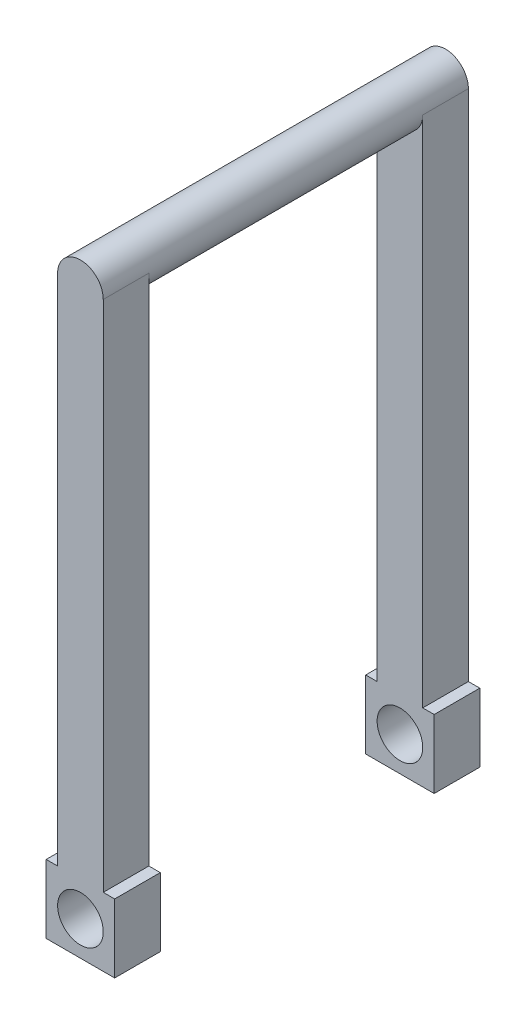
from build123d import *

# Parameters (mm, degrees)
SKETCH2_R           = 6.35
BOSS_EXTRUDE1_DEPTH = 76.2
SKETCH3_W           = 12.7
SKETCH3_H           = 152.4
BOSS_EXTRUDE2_DEPTH = 12.7
BOSS_EXTRUDE3_DEPTH = 12.7
SKETCH6_W           = 12.7
SKETCH6_H           = 152.4
BOSS_EXTRUDE4_DEPTH = 12.7
BOSS_EXTRUDE5_DEPTH = 12.7
SKETCH8_W           = 19.05
SKETCH8_H           = 19.05
BOSS_EXTRUDE6_DEPTH = 101.6
SKETCH9_W           = 76.2
SKETCH9_H           = 29.319846112
CUT_EXTRUDE1_DEPTH  = 198.12
CUT_EXTRUDE2_DEPTH  = 102.6


with BuildPart() as part:
    # Sketch2 → Boss-Extrude1 (new body)
    with BuildSketch(Plane.XY):
        Circle(SKETCH2_R)
    extrude(amount=BOSS_EXTRUDE1_DEPTH)

    # Sketch3 → Boss-Extrude2 (add)
    with BuildSketch(Plane.XY.offset(76.2)):
        with Locations((0, -76.2)):
            Rectangle(SKETCH3_W, SKETCH3_H)
    extrude(amount=BOSS_EXTRUDE2_DEPTH)

    # Sketch4 → Boss-Extrude3 (add)
    with BuildSketch(Plane.XY.offset(76.2)):
        with BuildLine():
            Line((-6.35, 0), (6.35, 0))
            ThreePointArc((6.35, 0), (0, 6.35), (-6.35, 0))
        make_face()
    extrude(amount=BOSS_EXTRUDE3_DEPTH)

    # Sketch6 → Boss-Extrude4 (add)
    with BuildSketch(Plane(origin=(0, 0, 0), x_dir=(-1, 0, 0), z_dir=(0, 0, -1))):
        with Locations((0, -76.2)):
            Rectangle(SKETCH6_W, SKETCH6_H)
    extrude(amount=BOSS_EXTRUDE4_DEPTH)

    # Sketch7 → Boss-Extrude5 (add)
    with BuildSketch(Plane(origin=(0, 0, 0), x_dir=(-1, 0, 0), z_dir=(0, 0, -1))):
        with BuildLine():
            Line((-6.35, 0), (6.35, 0))
            ThreePointArc((6.35, 0), (0, 6.35), (-6.35, 0))
        make_face()
    extrude(amount=BOSS_EXTRUDE5_DEPTH)

    # Sketch8 → Boss-Extrude6 (add)
    with BuildSketch(Plane(origin=(0, 0, -12.7), x_dir=(-1, 0, 0), z_dir=(0, 0, -1))):
        with Locations((0, -152.4)):
            Rectangle(SKETCH8_W, SKETCH8_H)
    extrude(amount=-BOSS_EXTRUDE6_DEPTH)

    # Sketch9 → Cut-Extrude1 (cut)
    with BuildSketch(Plane(origin=(9.525, 0, 0), x_dir=(0, 0, -1), z_dir=(1, 0, 0))):
        with Locations((-38.1, -157.534923056)):
            Rectangle(SKETCH9_W, SKETCH9_H)
    extrude(amount=-CUT_EXTRUDE1_DEPTH, mode=Mode.SUBTRACT)

    # Sketch10 → Cut-Extrude2 (cut, through all)
    with BuildSketch(Plane.XY.offset(88.9)):
        with BuildLine():
            ThreePointArc((6.35, -152.4), (0, -146.05), (-6.35, -152.4))
            Line((-6.35, -152.4), (6.35, -152.4))
        make_face()
        with BuildLine():
            Line((6.35, -152.4), (-6.35, -152.4))
            ThreePointArc((-6.35, -152.4), (0, -158.75), (6.35, -152.4))
        make_face()
    extrude(amount=-CUT_EXTRUDE2_DEPTH, mode=Mode.SUBTRACT)


solid = part.part
